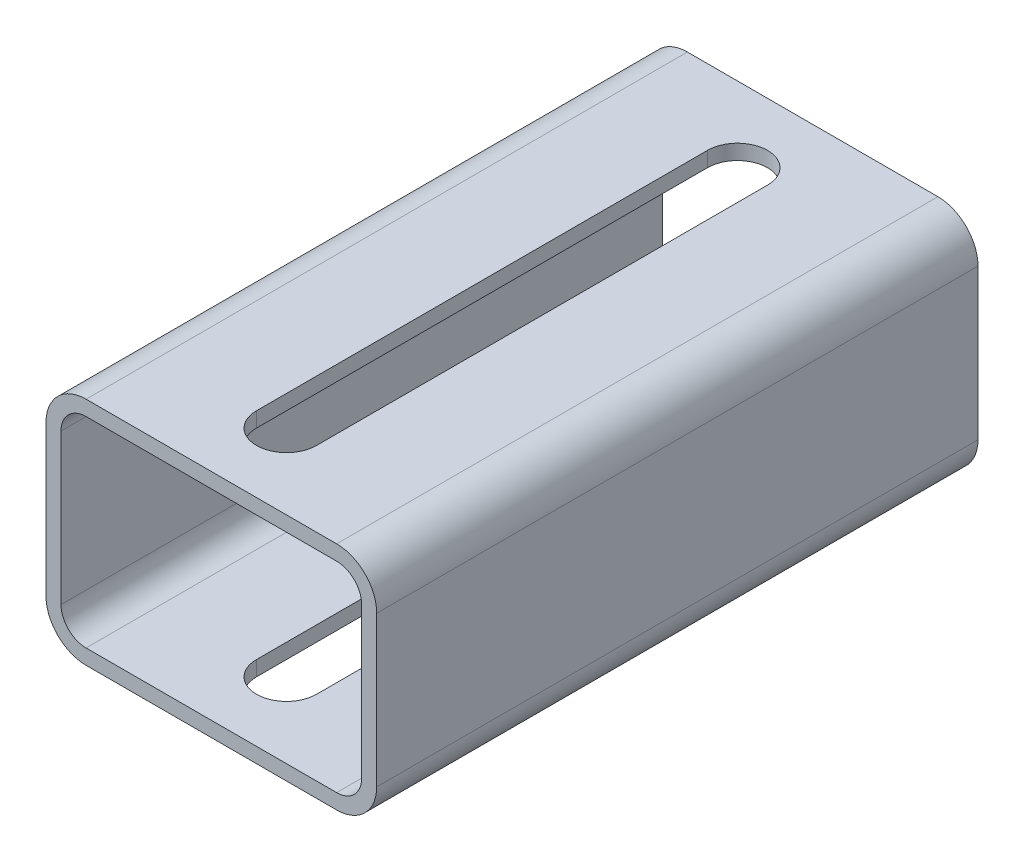
from build123d import *

# Parameters (mm, degrees)
EXTRUDE_THIN1_DEPTH     = 60
CUT_EXTRUDE1_DEPTH      = 1
CUT_EXTRUDE1_DEPTH_BACK = 47


with BuildPart() as part:
    # Sketch1 → Extrude-Thin1 (new body, symmetric)
    with BuildSketch(Plane.XY):
        with BuildLine():
            Line((-33, 15), (-33, -15))
            ThreePointArc((-33, -15), (-30.656854249, -20.656854249), (-25, -23))
            Line((-25, -23), (25, -23))
            ThreePointArc((25, -23), (30.656854249, -20.656854249), (33, -15))
            Line((33, -15), (33, 15))
            ThreePointArc((33, 15), (30.656854249, 20.656854249), (25, 23))
            Line((25, 23), (-25, 23))
            ThreePointArc((-25, 23), (-30.656854249, 20.656854249), (-33, 15))
        make_face()
        with BuildLine():
            Line((-30, 15), (-30, -15))
            ThreePointArc((-30, -15), (-28.535533906, -18.535533906), (-25, -20))
            Line((-25, -20), (25, -20))
            ThreePointArc((25, -20), (28.535533906, -18.535533906), (30, -15))
            Line((30, -15), (30, 15))
            ThreePointArc((30, 15), (28.535533906, 18.535533906), (25, 20))
            Line((25, 20), (-25, 20))
            ThreePointArc((-25, 20), (-28.535533906, 18.535533906), (-30, 15))
        make_face(mode=Mode.SUBTRACT)
    extrude(amount=EXTRUDE_THIN1_DEPTH, both=True)

    # Sketch2 → Cut-Extrude1 (cut, two sides)
    with BuildSketch(Plane(origin=(0, 23, 0), x_dir=(1, 0, 0), z_dir=(0, 1, 0))) as cut_extrude1_sk:
        with BuildLine():
            Line((6, 45), (6, -45))
            ThreePointArc((6, -45), (0, -51), (-6, -45))
            Line((-6, -45), (-6, 45))
            ThreePointArc((-6, 45), (0, 51), (6, 45))
        make_face()
    extrude(amount=CUT_EXTRUDE1_DEPTH, mode=Mode.SUBTRACT)
    extrude(cut_extrude1_sk.sketch, amount=-CUT_EXTRUDE1_DEPTH_BACK, mode=Mode.SUBTRACT)


solid = part.part
